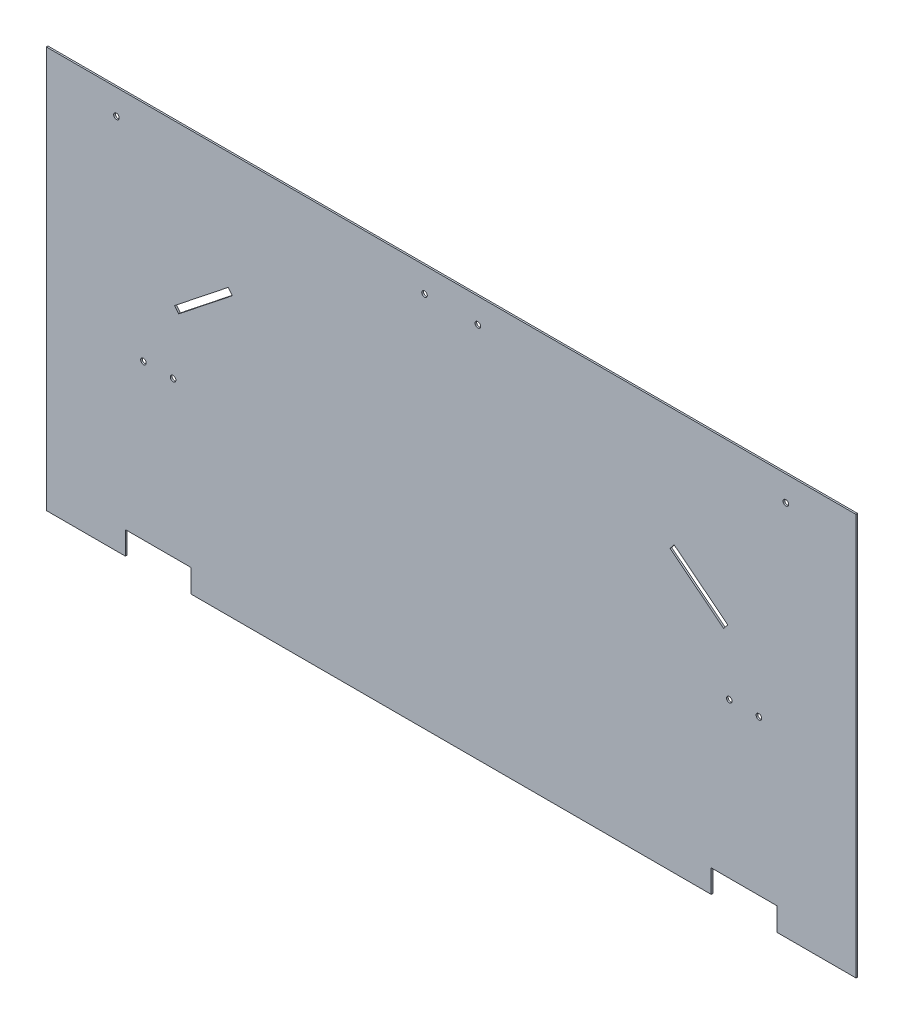
from build123d import *

# Parameters (mm, degrees)
SKETCH1_R           = 5.3578125
BOSS_EXTRUDE1_DEPTH = 3.175


with BuildPart() as part:
    # Sketch1 → Boss-Extrude1 (new body)
    with BuildSketch(Plane.XY):
        Polygon((781.05, 387.35), (-781.05, 387.35), (-781.05, -387.35), (-628.65, -387.35), (-628.65, -342.9), (-501.65, -342.9), (-501.65, -387.35), (501.65, -387.35), (501.65, -342.9), (628.65, -342.9), (628.65, -387.35), (781.05, -387.35), align=None)
        with Locations((-593.725, -44.45)):
            Circle(SKETCH1_R, mode=Mode.SUBTRACT)
        with Locations((-536.575, -44.45)):
            Circle(SKETCH1_R, mode=Mode.SUBTRACT)
        with Locations((536.575, -44.45)):
            Circle(SKETCH1_R, mode=Mode.SUBTRACT)
        with Locations((593.725, -44.45)):
            Circle(SKETCH1_R, mode=Mode.SUBTRACT)
        Polygon((-525.741660624, 69.011766046), (-533.633373454, 78.962186571), (-430.149, 161.036), (-422.25728717, 151.085579476), align=None, mode=Mode.SUBTRACT)
        with Locations((-645.795, 339.09)):
            Circle(SKETCH1_R, mode=Mode.SUBTRACT)
        with Locations((-51.435, 339.459169182)):
            Circle(SKETCH1_R, mode=Mode.SUBTRACT)
        Polygon((533.712268362, 79.061761082), (525.830130005, 69.103754509), (422.266861643, 151.077993427), (430.149, 161.036), align=None, mode=Mode.SUBTRACT)
        with Locations((51.435, 339.338450694)):
            Circle(SKETCH1_R, mode=Mode.SUBTRACT)
        with Locations((645.795, 339.09)):
            Circle(SKETCH1_R, mode=Mode.SUBTRACT)
    extrude(amount=BOSS_EXTRUDE1_DEPTH)


solid = part.part
